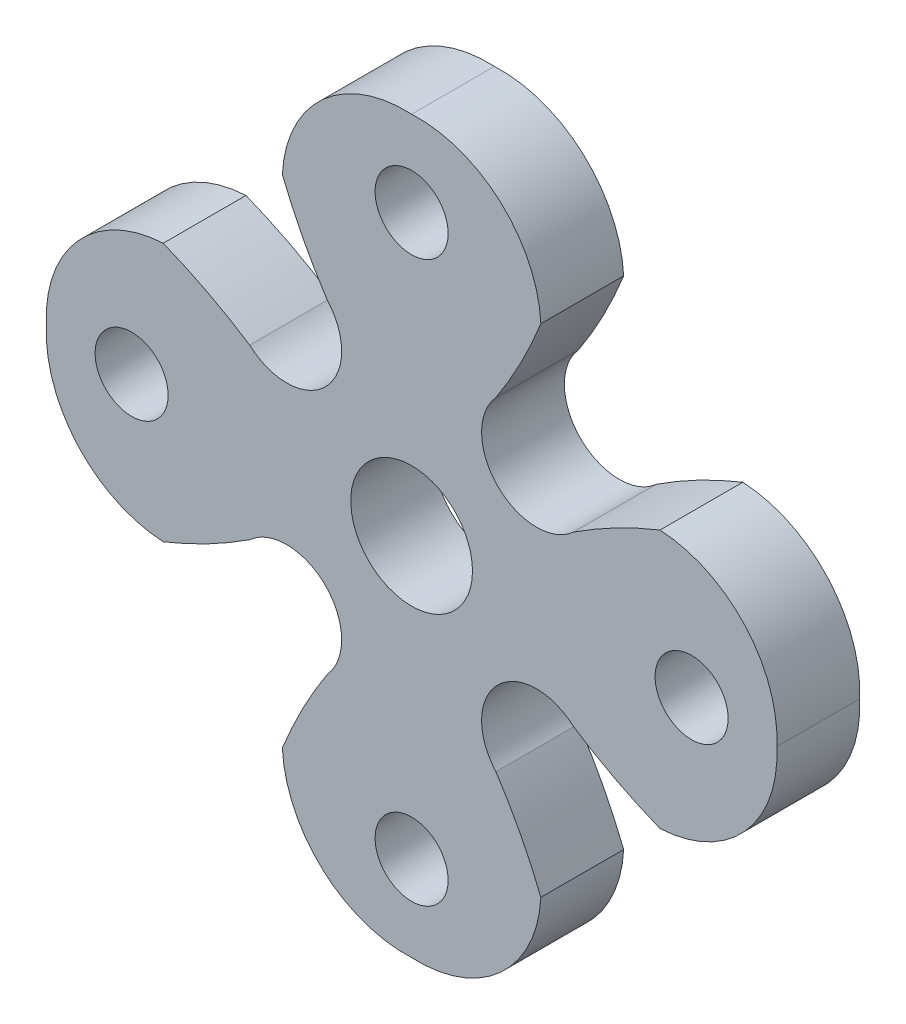
from build123d import *

# Parameters (mm, degrees)
SKETCH1_R           = 1.905
SKETCH1_R_2         = 3.175
BOSS_EXTRUDE1_DEPTH = 4.318


with BuildPart() as part:
    # Sketch1 → Boss-Extrude1 (new body)
    with BuildSketch(Plane.XY):
        with BuildLine():
            ThreePointArc((-6.74251391, 12.955482668), (-4.633472823, 17.399161687), (0, 19.05))
            ThreePointArc((0, 19.05), (4.633472823, 17.399161687), (6.74251391, 12.955482668))
            ThreePointArc((6.74251391, 12.955482668), (5.682842224, 10.643577378), (4.397291681, 8.449227827))
            ThreePointArc((4.397291681, 8.449227827), (4.490128061, 4.490128061), (8.449227827, 4.397291681))
            ThreePointArc((8.449227827, 4.397291681), (10.643577378, 5.682842224), (12.955482668, 6.74251391))
            ThreePointArc((12.955482668, 6.74251391), (17.399161687, 4.633472823), (19.05, 0))
            ThreePointArc((19.05, 0), (17.399161687, -4.633472823), (12.955482668, -6.74251391))
            ThreePointArc((12.955482668, -6.74251391), (10.643577378, -5.682842224), (8.449227827, -4.397291681))
            ThreePointArc((8.449227827, -4.397291681), (4.490128061, -4.490128061), (4.397291681, -8.449227827))
            ThreePointArc((4.397291681, -8.449227827), (5.682842224, -10.643577378), (6.74251391, -12.955482668))
            ThreePointArc((6.74251391, -12.955482668), (4.633472823, -17.399161687), (0, -19.05))
            ThreePointArc((0, -19.05), (-4.633472823, -17.399161687), (-6.74251391, -12.955482668))
            ThreePointArc((-6.74251391, -12.955482668), (-5.682842224, -10.643577378), (-4.397291681, -8.449227827))
            ThreePointArc((-4.397291681, -8.449227827), (-4.490128061, -4.490128061), (-8.449227827, -4.397291681))
            ThreePointArc((-8.449227827, -4.397291681), (-10.643577378, -5.682842224), (-12.955482668, -6.74251391))
            ThreePointArc((-12.955482668, -6.74251391), (-17.399161687, -4.633472823), (-19.05, 0))
            ThreePointArc((-19.05, 0), (-17.399161687, 4.633472823), (-12.955482668, 6.74251391))
            ThreePointArc((-12.955482668, 6.74251391), (-10.643577378, 5.682842224), (-8.449227827, 4.397291681))
            ThreePointArc((-8.449227827, 4.397291681), (-4.490128061, 4.490128061), (-4.397291681, 8.449227827))
            ThreePointArc((-4.397291681, 8.449227827), (-5.682842224, 10.643577378), (-6.74251391, 12.955482668))
        make_face()
        with Locations((0, 14.605)):
            Circle(SKETCH1_R, mode=Mode.SUBTRACT)
        with Locations((14.605, 0)):
            Circle(SKETCH1_R, mode=Mode.SUBTRACT)
        with Locations((0, -14.605)):
            Circle(SKETCH1_R, mode=Mode.SUBTRACT)
        with Locations((-14.605, 0)):
            Circle(SKETCH1_R, mode=Mode.SUBTRACT)
        Circle(SKETCH1_R_2, mode=Mode.SUBTRACT)
    extrude(amount=BOSS_EXTRUDE1_DEPTH)


solid = part.part
